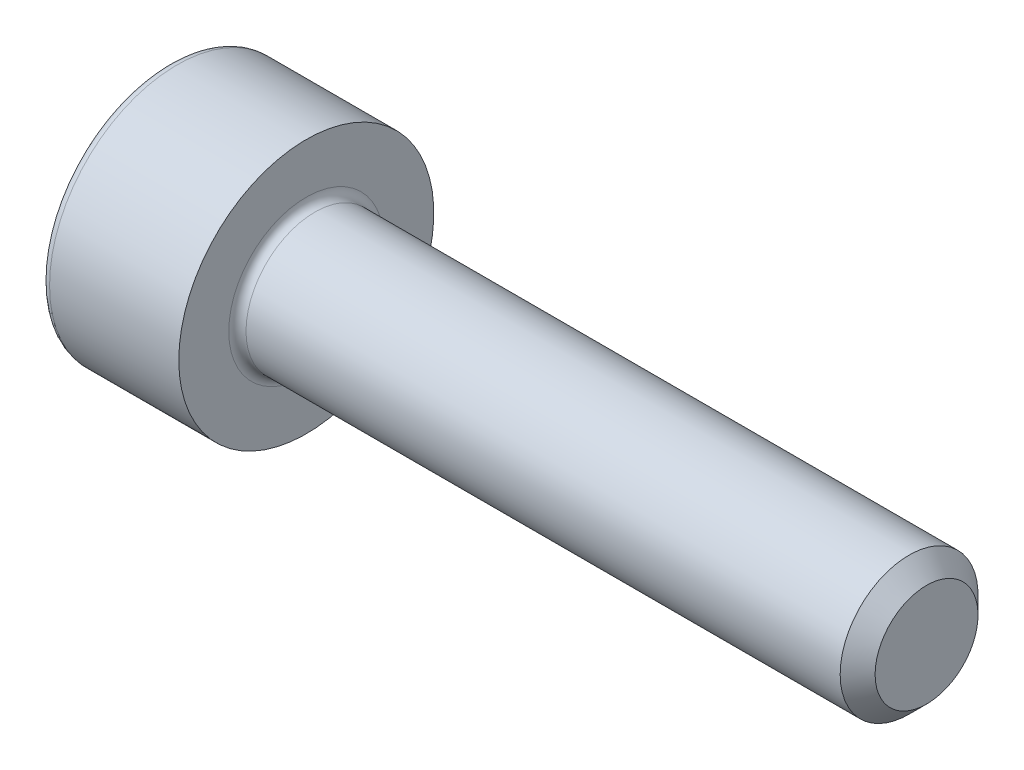
from build123d import *

# Parameters (mm, degrees)
CUT_EXTRUDE1_DEPTH = 1.1


with BuildPart() as part:
    # Sketch1 → Revolve1 (revolve)
    with BuildSketch(Plane.XY):
        with BuildLine():
            Line((8.7465, 1), (0.125, 1))
            ThreePointArc((0.125, 1), (0.036611652, 1.036611652), (0, 1.125))
            Line((0, 1.125), (0, 1.85))
            Line((0, 1.85), (-1.875, 1.85))
            ThreePointArc((-1.875, 1.85), (-1.963388348, 1.813388348), (-2, 1.725))
            Line((-2, 1.725), (-2, 0))
            Line((-2, 0), (9, 0))
            Line((9, 0), (9, 0.7465))
            Line((9, 0.7465), (8.7465, 1))
        make_face()
    revolve(axis=Axis((-2, 0, 0), (1, 0, 0)))

    # Sketch2 → Cut-Extrude1 (cut)
    with BuildSketch(Plane.ZY.offset(2)):
        Polygon((0.75, 0.433012702), (0, 0.866025404), (-0.75, 0.433012702), (-0.75, -0.433012702), (0, -0.866025404), (0.75, -0.433012702), align=None)
    extrude(amount=-CUT_EXTRUDE1_DEPTH, mode=Mode.SUBTRACT)


solid = part.part
